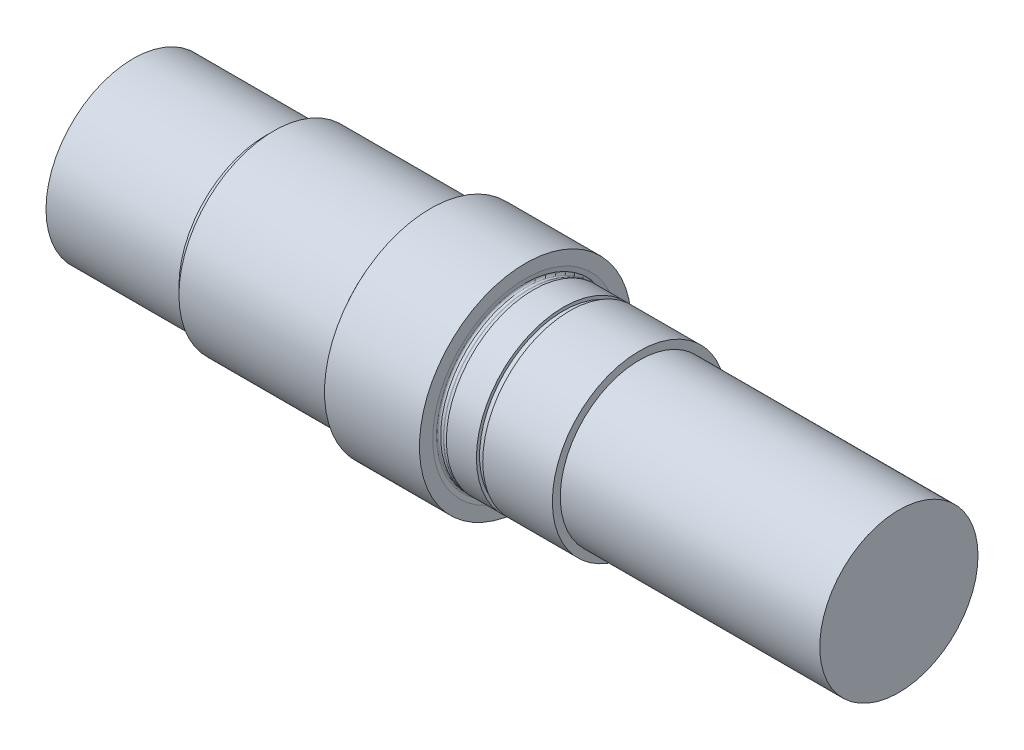
from build123d import *


with BuildPart() as part:
    # Skizze1 → Rotation1 (revolve)
    with BuildSketch(Plane(origin=(0, 0, 0), x_dir=(1, 0, 0), z_dir=(0, 1, 0))):
        with BuildLine():
            Line((0, 0), (0, 27.5))
            Line((0, 27.5), (42, 27.5))
            Line((42, 27.5), (43.043315314, 27.220444504))
            ThreePointArc((43.043315314, 27.220444504), (43.120291025, 27.205133083), (43.198606741, 27.2))
            Line((43.198606741, 27.2), (44.067315551, 27.2))
            ThreePointArc((44.067315551, 27.2), (44.544808566, 27.417606104), (44.693842758, 27.920737106))
            Line((44.693842758, 27.920737106), (44.5, 29.3))
            Line((44.5, 29.3), (44.5, 30))
            Line((44.5, 30), (91.5, 30))
            Line((91.5, 30), (92.543315314, 29.720444504))
            ThreePointArc((92.543315314, 29.720444504), (92.620291025, 29.705133083), (92.698606741, 29.7))
            Line((92.698606741, 29.7), (93.6, 29.7))
            ThreePointArc((93.6, 29.7), (94.052155597, 29.905594985), (94.19444145, 30.38148228))
            Line((94.19444145, 30.38148228), (94, 31.8))
            Line((94, 31.8), (94, 33.5))
            Line((94, 33.5), (124, 33.5))
            Line((124, 33.5), (124, 29.3))
            Line((124, 29.3), (123.80555855, 27.88148228))
            ThreePointArc((123.80555855, 27.88148228), (123.947844403, 27.405594985), (124.4, 27.2))
            Line((124.4, 27.2), (125.301393259, 27.2))
            ThreePointArc((125.301393259, 27.2), (125.379708975, 27.205133083), (125.456684686, 27.220444504))
            Line((125.456684686, 27.220444504), (126.5, 27.5))
            Line((126.5, 27.5), (136, 27.5))
            Line((136, 27.5), (136, 26.5))
            Line((136, 26.5), (138, 26.5))
            Line((138, 26.5), (138, 27.5))
            Line((138, 27.5), (160, 27.5))
            Line((160, 27.5), (160, 25))
            Line((160, 25), (242, 25))
            Line((242, 25), (242, 0))
            Line((242, 0), (0, 0))
        make_face()
    revolve(axis=Axis((242, 0, 0), (-1, 0, 0)))


solid = part.part
